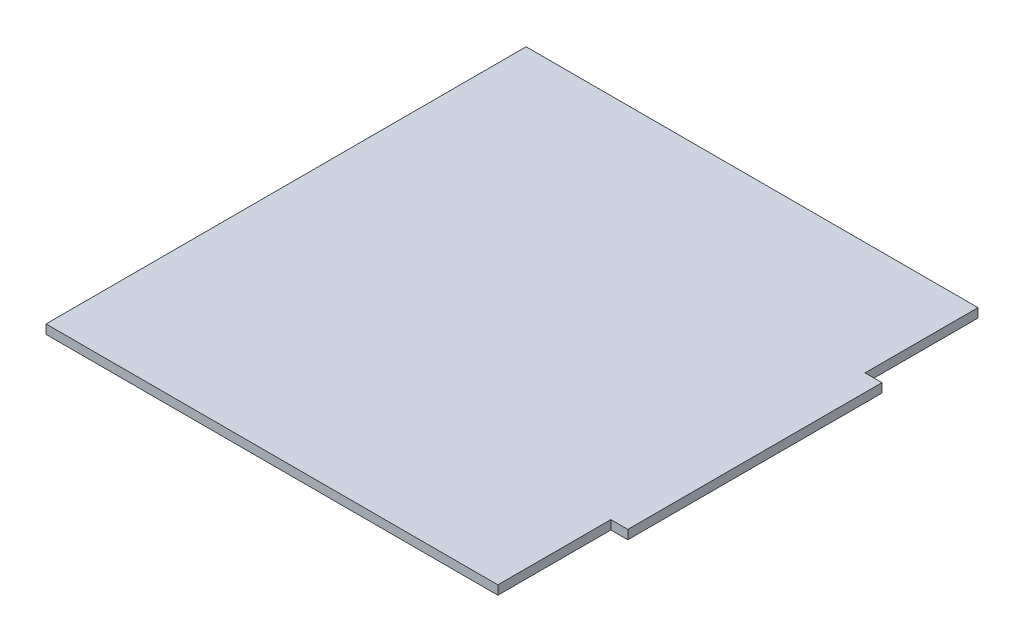
from build123d import *

# Parameters (mm, degrees)
SKETCH1_W           = 83
SKETCH1_H           = 85
BOSS_EXTRUDE1_DEPTH = 1.6
SKETCH2_W           = 3
SKETCH2_H           = 20
CUT_EXTRUDE1_DEPTH  = 10


with BuildPart() as part:
    # Sketch1 → Boss-Extrude1 (new body)
    with BuildSketch(Plane(origin=(0, 0, 0), x_dir=(1, 0, 0), z_dir=(0, 1, 0))):
        Rectangle(SKETCH1_W, SKETCH1_H)
    extrude(amount=BOSS_EXTRUDE1_DEPTH)

    # Sketch2 → Cut-Extrude1 (cut)
    with BuildSketch(Plane(origin=(0, 1.6, 0), x_dir=(1, 0, 0), z_dir=(0, 1, 0))):
        with Locations((40, 32.5)):
            Rectangle(SKETCH2_W, SKETCH2_H)
        with Locations((40, -32.5)):
            Rectangle(SKETCH2_W, SKETCH2_H)
    extrude(amount=-CUT_EXTRUDE1_DEPTH, mode=Mode.SUBTRACT)


solid = part.part
